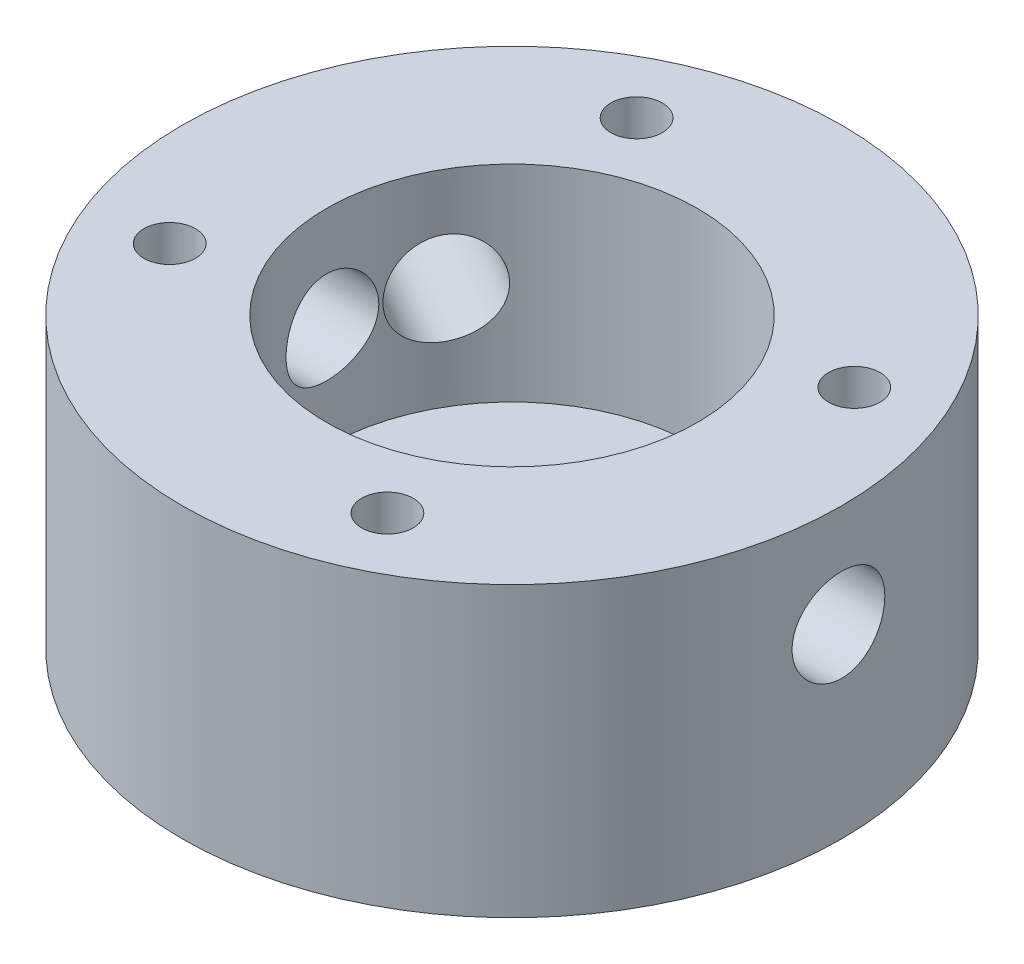
from build123d import *

# Parameters (mm, degrees)
F_4_5_4_5_DIAMETER_HOLE1_D           = 4.5
F_4_5_4_5_DIAMETER_HOLE1_ON_FACE_2_D = 4.5
F_4_5_4_5_DIAMETER_HOLE2_D           = 4.5
F_4_5_4_5_DIAMETER_HOLE2_DEPTH       = 18
F_4_5_4_5_DIAMETER_HOLE2_TIP         = 1.351936393
CIRPATTERN1_COUNT                    = 4


with BuildPart() as part:
    # Esboço1 → Revolução1 (revolve)
    with BuildSketch(Plane.XY):
        Polygon((3, -9), (16, -9), (16, 5), (9, 5), (9, -5), (3, -5), align=None)
    revolve(axis=Axis((0, -9, 0), (0, 1, 0)))

    # Ø4.5 (4.5) Diameter Hole1 (through all)
    with Locations(Plane(origin=(16, 0, 0), x_dir=(0, 0, 1), z_dir=(1, 0, 0))):
        with Locations((0, 0)):
            Hole(F_4_5_4_5_DIAMETER_HOLE1_D / 2)

    # Ø4.5 (4.5) Diameter Hole1 on face 2 (through all)
    with Locations(Plane(origin=(0, 0, 0), x_dir=(0, 0, 1), z_dir=(1, 0, 0))):
        with Locations((0, 0)):
            Hole(F_4_5_4_5_DIAMETER_HOLE1_ON_FACE_2_D / 2)

    # Ø4.5 (4.5) Diameter Hole2
    with Locations(Plane(origin=(-13.856406461, 0, -8), x_dir=(0, -1, 0), z_dir=(-0.8660254037844364, 0, -0.5000000000000041))):
        with Locations((0, 0)):
            Hole(F_4_5_4_5_DIAMETER_HOLE2_D / 2, depth=F_4_5_4_5_DIAMETER_HOLE2_DEPTH)
            with Locations((0, 0, -(F_4_5_4_5_DIAMETER_HOLE2_DEPTH + F_4_5_4_5_DIAMETER_HOLE2_TIP / 2))):  # 118° drill point
                Cone(0, F_4_5_4_5_DIAMETER_HOLE2_D / 2, F_4_5_4_5_DIAMETER_HOLE2_TIP, mode=Mode.SUBTRACT)

    # Sketch1 → M3x0.5 Tapped Hole1 (revolve, cut)
    with BuildSketch(Plane(origin=(-5.282728272, 5, -11.328847338), x_dir=(0, 0, 1), z_dir=(1, 0, 0))):
        Polygon((0, 0), (0, 12.751075774), (1.25, 12), (1.25, 0), align=None)
    m3x0_5_tapped_hole1 = revolve(axis=Axis((-5.282728272, 11.35, -11.328847338), (0, -1, 0)), mode=Mode.SUBTRACT)

    # CirPattern1: M3x0.5 Tapped Hole1 ×4 about axis
    cirpattern1_axis = Axis((0, 0, 0), (0, -1, 0))
    for i in range(1, CIRPATTERN1_COUNT):
        add(m3x0_5_tapped_hole1.rotate(cirpattern1_axis, i * 360 / CIRPATTERN1_COUNT), mode=Mode.SUBTRACT)


solid = part.part
